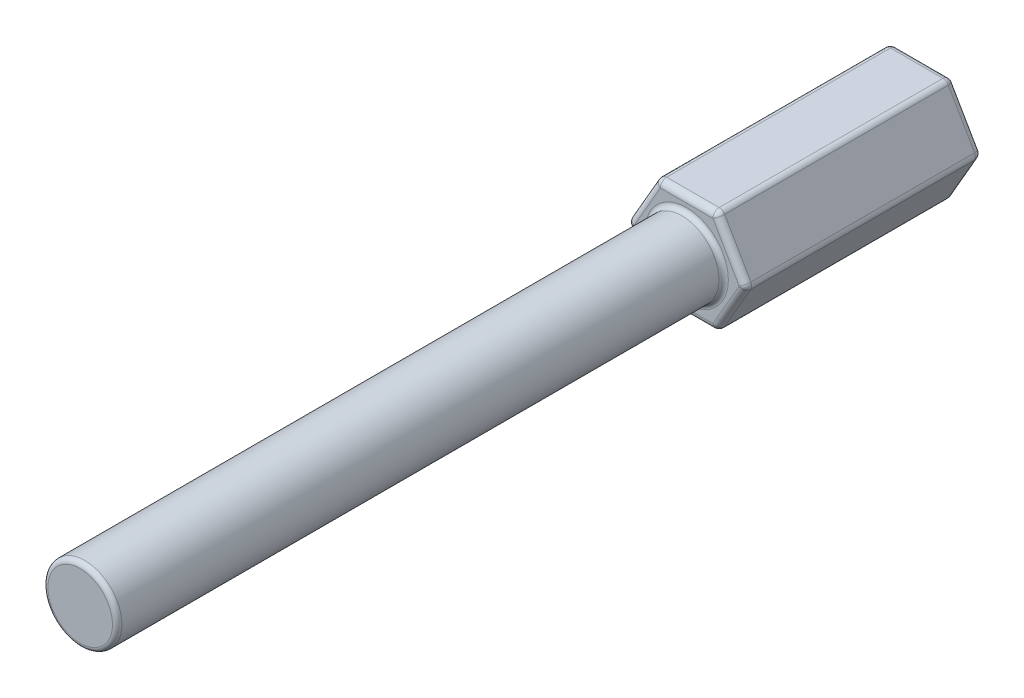
from build123d import *

# Parameters (mm, degrees)
BOSS_EXTRUDE1_DEPTH = 19.05
SKETCH2_R           = 2.9845
BOSS_EXTRUDE2_DEPTH = 48.895
FILLET1_R           = 0.381
FILLET2_R           = 0.381
FILLET3_R           = 0.508
FILLET4_R           = 0.508


with BuildPart() as part:
    # Sketch1 → Boss-Extrude1 (new body)
    with BuildSketch(Plane.XY):
        Polygon((2.410509543, -4.175125), (4.821019085, 0), (2.410509543, 4.175125), (-2.410509543, 4.175125), (-4.821019085, 0), (-2.410509543, -4.175125), align=None)
    extrude(amount=BOSS_EXTRUDE1_DEPTH)

    # Sketch2 → Boss-Extrude2 (add)
    with BuildSketch(Plane.XY.offset(19.05)):
        Circle(SKETCH2_R)
    extrude(amount=BOSS_EXTRUDE2_DEPTH)

    # Fillet1
    fillet1_edges = [part.edges().sort_by_distance(p)[0] for p in [
        (-2.9845, 0, 67.945),
    ]]
    fillet(fillet1_edges, radius=FILLET1_R)

    # Fillet2
    fillet2_edges = [part.edges().sort_by_distance(p)[0] for p in [
        (-2.9845, 0, 19.05),
    ]]
    fillet(fillet2_edges, radius=FILLET2_R)

    # Fillet3
    fillet3_edges = [part.edges().sort_by_distance(p)[0] for p in [
        (3.615764314, 2.0875625, 19.05),
        (0, 4.175125, 19.05),
        (-3.615764314, 2.0875625, 19.05),
        (-3.615764314, -2.0875625, 19.05),
        (0, -4.175125, 19.05),
        (-3.615764314, -2.0875625, 0),
        (-3.615764314, 2.0875625, 0),
        (0, 4.175125, 0),
        (3.615764314, 2.0875625, 0),
        (3.615764314, -2.0875625, 0),
        (0, -4.175125, 0),
        (3.615764314, -2.0875625, 19.05),
    ]]
    fillet(fillet3_edges, radius=FILLET3_R)

    # Fillet4
    fillet4_edges = [part.edges().sort_by_distance(p)[0] for p in [
        (4.821019085, 0, 9.525),
        (2.410509543, -4.175125, 9.525),
        (2.410509543, 4.175125, 9.525),
        (-2.410509543, -4.175125, 9.525),
        (-2.410509543, 4.175125, 9.525),
        (-4.821019085, 0, 9.525),
        (-4.634149245, 0, 0.136202851),
        (-2.317074623, 4.013290972, 0.136202851),
        (-2.317074623, -4.013290972, 0.136202851),
        (2.317074623, 4.013290972, 0.136202851),
        (2.317074623, -4.013290972, 0.136202851),
        (4.634149245, 0, 0.136202851),
        (-2.317074623, -4.013290972, 18.913797149),
        (-4.634149245, 0, 18.913797149),
        (2.317074623, -4.013290972, 18.913797149),
        (-2.317074623, 4.013290972, 18.913797149),
        (4.634149245, 0, 18.913797149),
        (2.317074623, 4.013290972, 18.913797149),
    ]]
    fillet(fillet4_edges, radius=FILLET4_R)


solid = part.part
